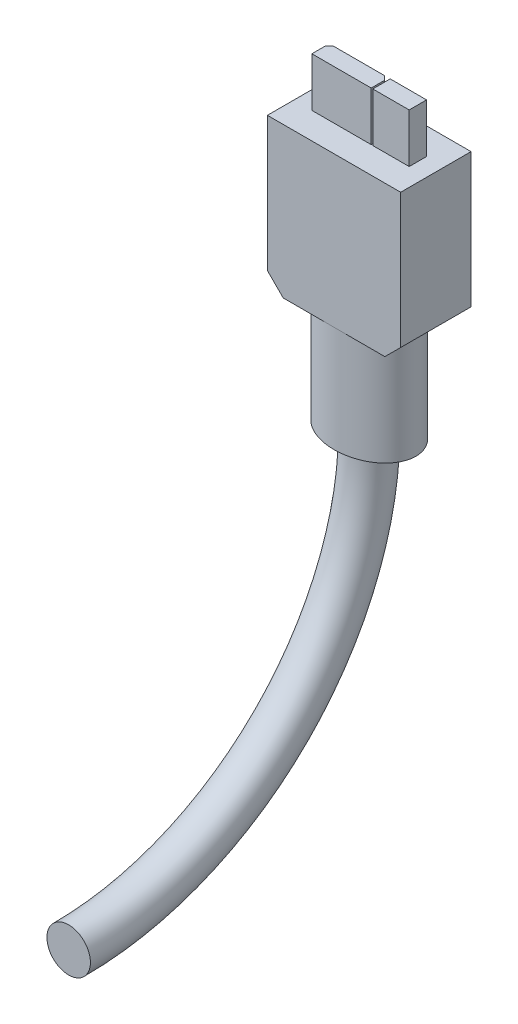
from build123d import *

# Parameters (mm, degrees)
SKETCH1_W           = 16.85
SKETCH1_H           = 8.9
BOSS_EXTRUDE1_DEPTH = 19
SKETCH2_W           = 7.5
SKETCH2_H           = 2.2
SKETCH2_W_2         = 4.6
BOSS_EXTRUDE2_DEPTH = 6.2
CHAMFER1_SIZE       = 0.5
SKETCH3_RX          = 5.9
SKETCH3_RY          = 4.45
BOSS_EXTRUDE3_DEPTH = 13.4
CHAMFER2_SIZE       = 2
SKETCH4_R           = 2.75


with BuildPart() as part:
    # Sketch1 → Boss-Extrude1 (new body)
    with BuildSketch(Plane(origin=(0, 0, 0), x_dir=(1, 0, 0), z_dir=(0, 1, 0))):
        with Locations((8.425, 4.45)):
            Rectangle(SKETCH1_W, SKETCH1_H)
    extrude(amount=BOSS_EXTRUDE1_DEPTH)

    # Sketch2 → Boss-Extrude2 (add)
    with BuildSketch(Plane(origin=(0, 19, 0), x_dir=(1, 0, 0), z_dir=(0, 1, 0))):
        with Locations((6.025, 4.45)):
            Rectangle(SKETCH2_W, SKETCH2_H)
        with Locations((12.275, 4.45)):
            Rectangle(SKETCH2_W_2, SKETCH2_H)
    extrude(amount=BOSS_EXTRUDE2_DEPTH)

    # Chamfer1
    chamfer1_edges = [part.edges().sort_by_distance(p)[0] for p in [
        (2.275, 22.1, -5.55),
        (9.775, 22.1, -5.55),
    ]]
    chamfer(chamfer1_edges, length=CHAMFER1_SIZE)

    # Sketch3 → Boss-Extrude3 (add)
    with BuildSketch(Plane.XZ):
        with Locations(Location((8.425, -4.45), (0, 0, 180))):
            Ellipse(SKETCH3_RX, SKETCH3_RY)
    extrude(amount=BOSS_EXTRUDE3_DEPTH)

    # Chamfer2
    chamfer2_edges = [part.edges().sort_by_distance(p)[0] for p in [
        (16.85, 0, -4.45),
        (0, 0, -4.45),
    ]]
    chamfer(chamfer2_edges, length=CHAMFER2_SIZE)

    # Sweep2: sweep along a path in Sketch6
    with BuildLine(Plane(origin=(0, 0, 0), x_dir=(0, 0, -1), z_dir=(1, 0, 0))) as sweep2_path:
        ThreePointArc((4.45, -13.4), (-6.679942315, -40.270057685), (-33.55, -51.4))
    # Sketch4 → Sweep2 (sweep)
    with BuildSketch(Plane.XZ.offset(13.4)):
        with Locations((8.425, -4.45)):
            Circle(SKETCH4_R)
    sweep(path=sweep2_path.line)


solid = part.part
